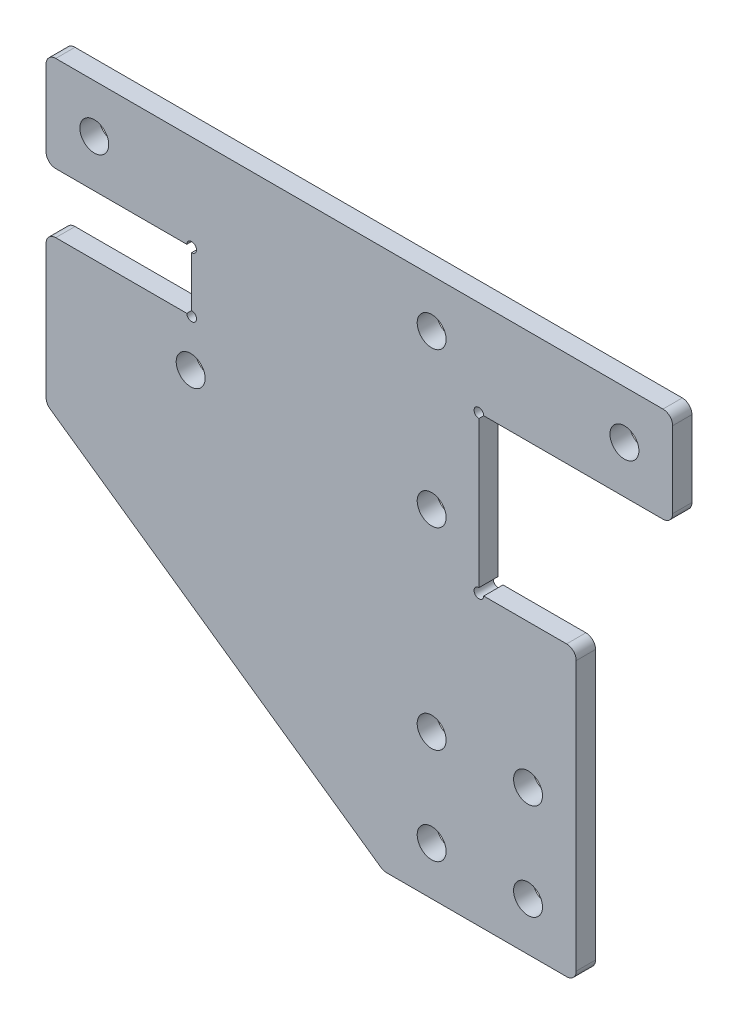
from build123d import *

# Parameters (mm, degrees)
SKETCH_1_R          = 1.5
EXTRUDE_1_DEPTH     = 2
SKETCH_2_R          = 0.5
CUT_EXTRUDE_1_DEPTH = 10
FILLET_2_R          = 1


with BuildPart() as part:
    # 草图1 → 凸台-拉伸1 (new body)
    with BuildSketch(Plane.XY):
        Polygon((15, -35), (15, -5.1), (4.9, -5.1), (4.9, 11.1), (25, 11.1), (25, 21), (-40, 21), (-40, 11.1), (-24.9, 11.1), (-24.9, 4.9), (-40, 4.9), (-40, -10.492736163), (-5, -35), align=None)
        with Locations((-35, 16)):
            Circle(SKETCH_1_R, mode=Mode.SUBTRACT)
        with Locations((10, -30)):
            Circle(SKETCH_1_R, mode=Mode.SUBTRACT)
        with Locations((10, -20)):
            Circle(SKETCH_1_R, mode=Mode.SUBTRACT)
        with Locations((0, 16)):
            Circle(SKETCH_1_R, mode=Mode.SUBTRACT)
        with Locations((20, 16)):
            Circle(SKETCH_1_R, mode=Mode.SUBTRACT)
        with Locations((-25, 0)):
            Circle(SKETCH_1_R, mode=Mode.SUBTRACT)
        Circle(SKETCH_1_R, mode=Mode.SUBTRACT)
        with Locations((0, -20)):
            Circle(SKETCH_1_R, mode=Mode.SUBTRACT)
        with Locations((0, -30)):
            Circle(SKETCH_1_R, mode=Mode.SUBTRACT)
    extrude(amount=EXTRUDE_1_DEPTH)

    # 草图2 → 切除-拉伸1 (cut)
    with BuildSketch(Plane(origin=(0, 0, 0), x_dir=(-1, 0, 0), z_dir=(0, 0, -1))):
        with Locations((-4.9, 11.1)):
            Circle(SKETCH_2_R)
        with Locations((-4.9, -5.1)):
            Circle(SKETCH_2_R)
        with Locations((24.9, 11.1)):
            Circle(SKETCH_2_R)
        with Locations((24.9, 4.9)):
            Circle(SKETCH_2_R)
    extrude(amount=-CUT_EXTRUDE_1_DEPTH, mode=Mode.SUBTRACT)

    # 圆角2
    fillet_2_edges = [part.edges().sort_by_distance(p)[0] for p in [
        (-40, 11.1, 1),
        (-40, 21, 1),
        (25, 21, 1),
        (25, 11.1, 1),
        (15, -5.1, 1),
        (15, -35, 1),
        (-5, -35, 1),
        (-40, -10.492736163, 1),
        (-40, 4.9, 1),
    ]]
    fillet(fillet_2_edges, radius=FILLET_2_R)


solid = part.part
